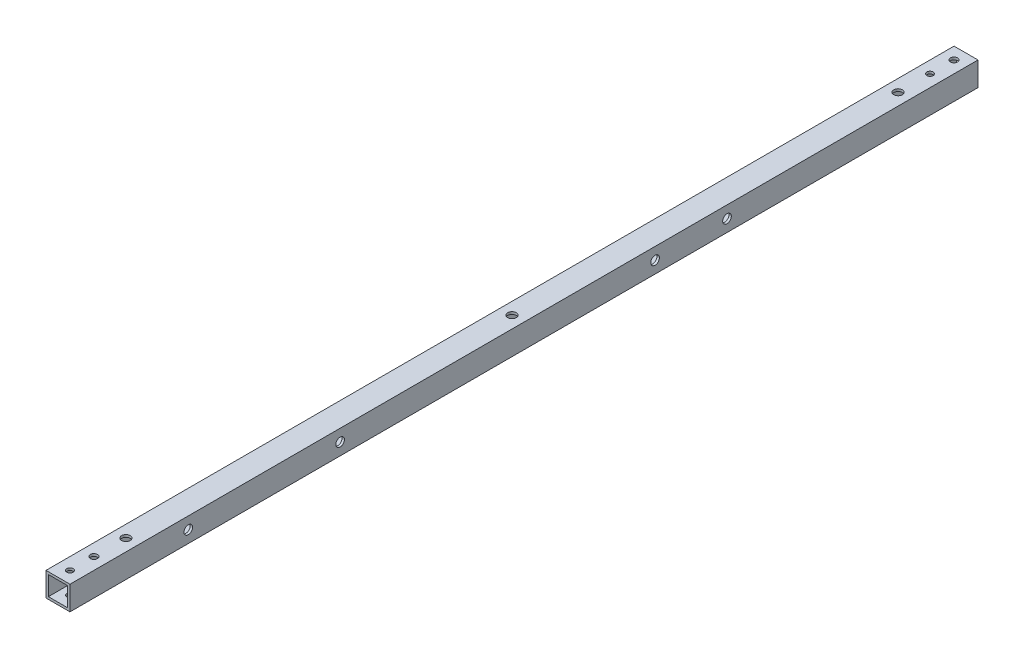
from build123d import *

# Parameters (mm, degrees)
SKETCH_1_W                  = 15
SKETCH_1_H                  = 15
SKETCH_1_W_2                = 12
SKETCH_1_H_2                = 12
EXTRUDE_1_DEPTH             = 568
SKETCH_5_R                  = 2
SKETCH_5_R_2                = 2.25
SKETCH_5_R_3                = 2.7
CUT_EXTRUDE_4_DEPTH         = 20
SKETCH_9_R                  = 2.7
CUT_EXTRUDE_6_DEPTH         = 40
SKETCH_10_R                 = 5
CUT_EXTRUDE_7_DEPTH         = 5
HOLE_WIZARD_10_0_10_2_D     = 10
HOLE_WIZARD_10_0_10_2_DEPTH = 1.5


with BuildPart() as part:
    # ｽｹｯﾁ1 → ﾎﾞｽ - 押し出し1 (new body)
    with BuildSketch(Plane.XY):
        Rectangle(SKETCH_1_W, SKETCH_1_H)
        Rectangle(SKETCH_1_W_2, SKETCH_1_H_2, mode=Mode.SUBTRACT)
    extrude(amount=EXTRUDE_1_DEPTH)

    # ｽｹｯﾁ5 → ｶｯﾄ - 押し出し4 (cut)
    with BuildSketch(Plane(origin=(0, -7.5, 0), x_dir=(-1, 0, 0), z_dir=(0, -1, 0))):
        with Locations((0, -22.5)):
            Circle(SKETCH_5_R)
        with Locations((0, -7.5)):
            Circle(SKETCH_5_R_2)
        with Locations((0, -560.5)):
            Circle(SKETCH_5_R)
        with Locations((0, -545.5)):
            Circle(SKETCH_5_R_2)
        with Locations((0, -42.5)):
            Circle(SKETCH_5_R_3)
        with Locations((0, -284)):
            Circle(SKETCH_5_R_3)
        with Locations((0, -525.5)):
            Circle(SKETCH_5_R_3)
    extrude(amount=-CUT_EXTRUDE_4_DEPTH, mode=Mode.SUBTRACT)

    # ｽｹｯﾁ9 → ｶｯﾄ - 押し出し6 (cut)
    with BuildSketch(Plane(origin=(7.5, 0, 0), x_dir=(0, 0, -1), z_dir=(1, 0, 0))):
        with Locations((-494, 0)):
            Circle(SKETCH_9_R)
        with Locations((-399, 0)):
            Circle(SKETCH_9_R)
        with Locations((-202, 0)):
            Circle(SKETCH_9_R)
        with Locations((-157, 0)):
            Circle(SKETCH_9_R)
    extrude(amount=-CUT_EXTRUDE_6_DEPTH, mode=Mode.SUBTRACT)

    # ｽｹｯﾁ10 → ｶｯﾄ - 押し出し7 (cut)
    with BuildSketch(Plane.ZY.offset(7.5)):
        with Locations((157, 0)):
            Circle(SKETCH_10_R)
        with Locations((202, 0)):
            Circle(SKETCH_10_R)
        with Locations((399, 0)):
            Circle(SKETCH_10_R)
        with Locations((494, 0)):
            Circle(SKETCH_10_R)
    extrude(amount=-CUT_EXTRUDE_7_DEPTH, mode=Mode.SUBTRACT)

    # Ø10.0 (10) 直径の穴2
    with Locations(Plane(origin=(0, -7.5, 0), x_dir=(-1, 0, 0), z_dir=(0, -1, 0))):
        with Locations((0, -42.5), (0, -284), (0, -525.5)):
            Hole(HOLE_WIZARD_10_0_10_2_D / 2, depth=HOLE_WIZARD_10_0_10_2_DEPTH)


solid = part.part
